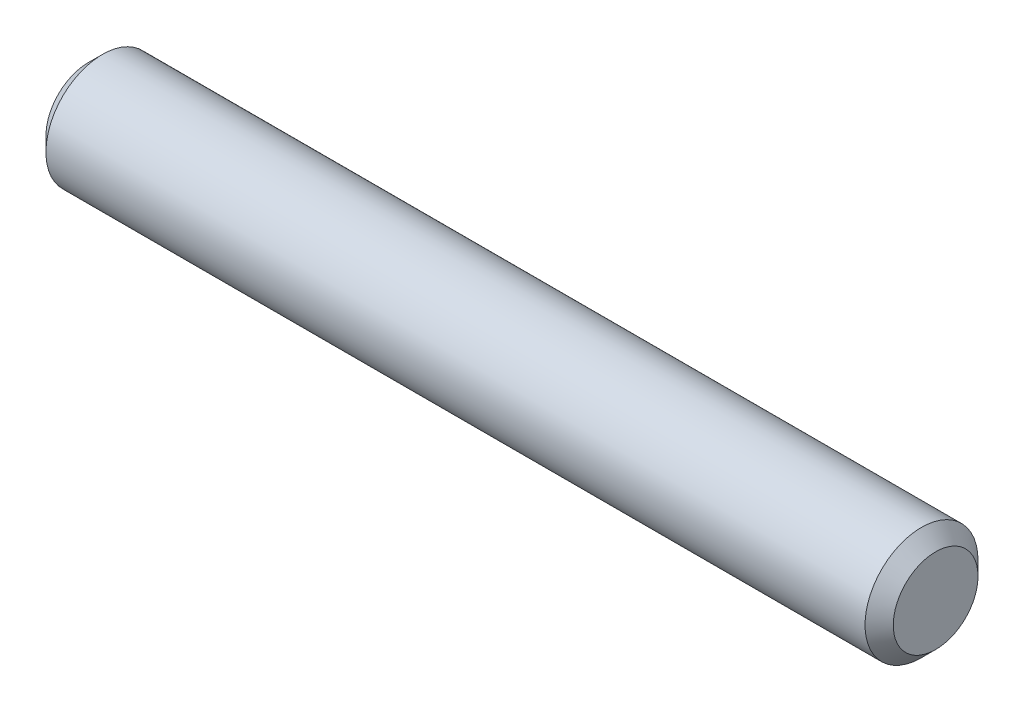
from build123d import *

# Parameters (mm, degrees)
SKETCH1_R           = 2
BOSS_EXTRUDE1_DEPTH = 15
CHAMFER1_SIZE       = 0.5


with BuildPart() as part:
    # Sketch1 → Boss-Extrude1 (new body, symmetric)
    with BuildSketch(Plane(origin=(0, 0, 0), x_dir=(0, 0, -1), z_dir=(1, 0, 0))):
        Circle(SKETCH1_R)
    extrude(amount=BOSS_EXTRUDE1_DEPTH, both=True)

    # Chamfer1
    chamfer1_edges = [part.edges().sort_by_distance(p)[0] for p in [
        (-15, 0, 2),
        (15, 0, 2),
    ]]
    chamfer(chamfer1_edges, length=CHAMFER1_SIZE)


solid = part.part
